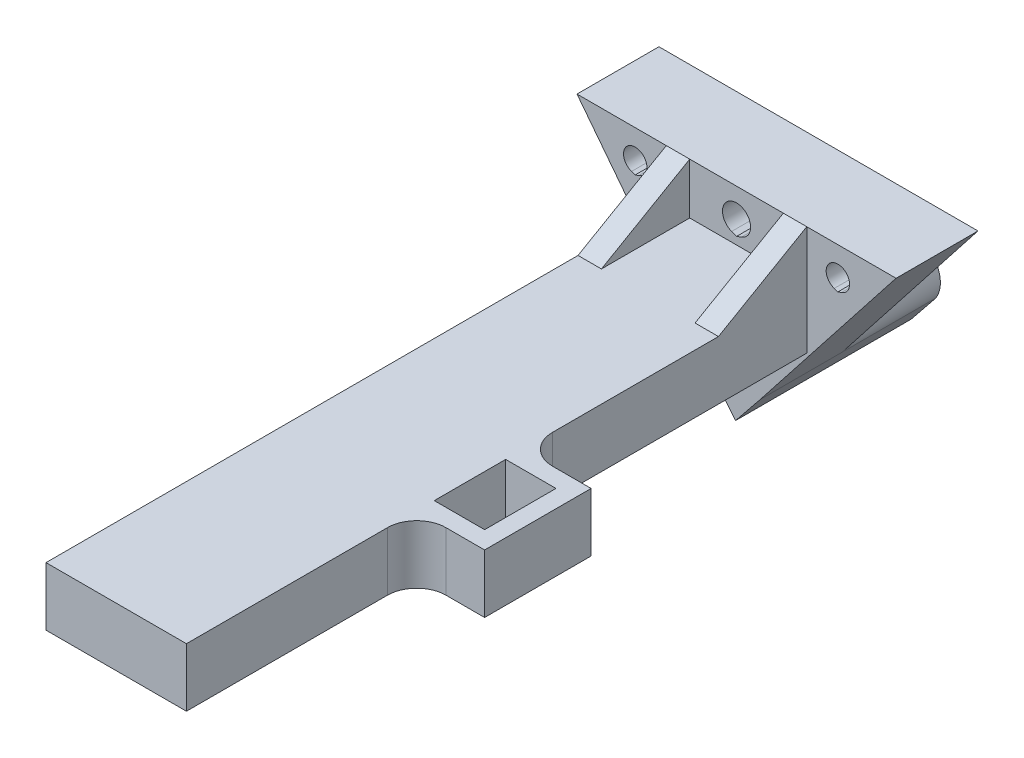
from build123d import *

# Parameters (mm, degrees)
SKETCH1_W            = 12
SKETCH1_H            = 60
BOSS_EXTRUDE1_DEPTH  = 1
SKETCH4_W            = 12
SKETCH4_H            = 60
BOSS_EXTRUDE5_DEPTH  = 4
SKETCH3_W            = 0.442585723
SKETCH3_H            = 46.400729484
SKETCH3_W_2          = 0.4
CUT_EXTRUDE1_DEPTH   = 3
BOSS_EXTRUDE6_DEPTH  = 7
BOSS_EXTRUDE11_DEPTH = 8
BOSS_EXTRUDE12_DEPTH = 2
BOSS_EXTRUDE13_DEPTH = 0.75
BOSS_EXTRUDE15_DEPTH = 2
BOSS_EXTRUDE16_DEPTH = 5
FILLET1_R            = 2.5
FILLET2_R            = 2.5


with BuildPart() as part:
    # Sketch1 → Boss-Extrude1 (new body)
    with BuildSketch(Plane(origin=(0, 0, 0), x_dir=(1, 0, 0), z_dir=(0, 1, 0))):
        with Locations((-1.342029662, -10.461538462)):
            Rectangle(SKETCH1_W, SKETCH1_H)
    extrude(amount=BOSS_EXTRUDE1_DEPTH)

    # Sketch4 → Boss-Extrude5 (add)
    with BuildSketch(Plane(origin=(0, 0, 0), x_dir=(1, 0, 0), z_dir=(0, 1, 0))):
        with Locations((-1.342029662, -10.461538462)):
            Rectangle(SKETCH4_W, SKETCH4_H)
        Polygon((-2.096130055, -33.457130572), (-6.384615385, -37.75443168), (-6.384611455, -29.168649172), align=None, mode=Mode.SUBTRACT)
        Polygon((2.908277834, -38.461538462), (-5.677508603, -38.461538462), (-1.384615385, -34.168645243), align=None, mode=Mode.SUBTRACT)
        Polygon((-1.38975443, -32.749302861), (-5.677336591, -28.461186458), (-1.384615385, -24.168121227), (2.898997747, -28.451734358), align=None, mode=Mode.SUBTRACT)
        Polygon((-2.091498793, -23.461237818), (-6.384610808, -27.754427103), (-6.384606877, -19.168129734), align=None, mode=Mode.SUBTRACT)
        Polygon((-1.384401984, -22.754128282), (-5.676963509, -18.461572954), (-1.384618257, -14.16814285), (2.90844487, -18.461204162), align=None, mode=Mode.SUBTRACT)
        Polygon((-2.094846949, -13.457914458), (-6.38460623, -17.742175237), (-6.38460623, -9.168156991), align=None, mode=Mode.SUBTRACT)
        Polygon((3.615384615, -29.168645243), (3.615384615, -37.75443168), (-0.749170508, -33.533200366), align=None, mode=Mode.SUBTRACT)
        Polygon((3.615384615, -19.168465252), (3.615384615, -27.753907665), (-0.677336591, -23.461186458), align=None, mode=Mode.SUBTRACT)
        Polygon((3.615384615, -17.754251693), (-0.676897524, -13.461506969), (3.615384615, -9.169224829), align=None, mode=Mode.SUBTRACT)
        Polygon((-6.384597723, 0.832144172), (-2.091409836, -3.461043715), (-6.384601653, -7.753916614), align=None, mode=Mode.SUBTRACT)
        Polygon((2.908517821, -8.460971372), (-1.387204346, -12.751178894), (-5.677010576, -8.461229413), (-1.384615385, -4.167838166), align=None, mode=Mode.SUBTRACT)
        Polygon((-1.385221722, -2.75490806), (-5.679497842, 1.537745361), (-1.38541394, 5.831829263), (2.908210299, 1.538205024), align=None, mode=Mode.SUBTRACT)
        Polygon((-2.089578329, 6.535993652), (-6.3837953, 2.241776681), (-6.384597078, 2.240974904), (-6.384597078, 2.242578156), (-6.384593146, 10.83100847), align=None, mode=Mode.SUBTRACT)
        Polygon((-5.677832652, 11.538461538), (2.912889557, 11.538461538), (-1.382471548, 7.243100433), align=None, mode=Mode.SUBTRACT)
        Polygon((3.615384615, -7.755011267), (-0.677821818, -3.462040655), (3.615384615, 0.831165778), align=None, mode=Mode.SUBTRACT)
        Polygon((3.615384615, 2.245379341), (-0.678307159, 6.538936044), (3.615384615, 10.832627818), align=None, mode=Mode.SUBTRACT)
    extrude(amount=-BOSS_EXTRUDE5_DEPTH)

    # Sketch3 → Cut-Extrude1 (cut)
    with BuildSketch(Plane.XZ.offset(4)):
        with Locations((3.436677476, 13.26117372)):
            Rectangle(SKETCH3_W, SKETCH3_H)
        with Locations((-6.184615385, 13.26117372)):
            Rectangle(SKETCH3_W_2, SKETCH3_H)
    extrude(amount=-CUT_EXTRUDE1_DEPTH, mode=Mode.SUBTRACT)

    # Sketch5 → Boss-Extrude6 (add)
    with BuildSketch(Plane(origin=(0, 0, -19.538461538), x_dir=(-1, 0, 0), z_dir=(0, 0, -1))):
        Polygon((-12.288789064, 5.355892869), (14.972848388, 5.355892869), (3.537352374, -9.415920613), (1.425918842, -12.033387248), (-0.689767913, -9.409188123), align=None)
        with BuildLine():
            Line((9.692725832, 1.966121199), (9.999443939, 1.857726092))
            Line((9.999443939, 1.857726092), (10.306162047, 1.966121199))
            ThreePointArc((10.306162047, 1.966121199), (9.999443939, 3.917921599), (9.692725832, 1.966121199))
        make_face(mode=Mode.SUBTRACT)
        with BuildLine():
            Line((-7.622102723, 1.966121199), (-7.315384615, 1.857726092))
            Line((-7.315384615, 1.857726092), (-7.008666508, 1.966121199))
            ThreePointArc((-7.008666508, 1.966121199), (-7.315384615, 3.917921599), (-7.622102723, 1.966121199))
        make_face(mode=Mode.SUBTRACT)
        with BuildLine():
            Line((0.921478569, 1.79402802), (1.342029662, 1.636661499))
            Line((1.342029662, 1.636661499), (1.762580755, 1.79402802))
            ThreePointArc((1.762580755, 1.79402802), (1.342029662, 4.117921599), (0.921478569, 1.79402802))
        make_face(mode=Mode.SUBTRACT)
    extrude(amount=-BOSS_EXTRUDE6_DEPTH)

    # Sketch5_3 → Boss-Extrude11 (add)
    with BuildSketch(Plane(origin=(0, 0, -19.538461538), x_dir=(-1, 0, 0), z_dir=(0, 0, -1))):
        with BuildLine():
            Line((3.537352374, -9.415920613), (1.425918842, -12.033387248))
            Line((1.425918842, -12.033387248), (-0.689767913, -9.409188123))
            ThreePointArc((-0.689767913, -9.409188123), (1.429900561, -5.57732435), (3.537352374, -9.415920613))
        make_face()
    extrude(amount=BOSS_EXTRUDE11_DEPTH)

    # Sketch11 → Boss-Extrude12 (add)
    with BuildSketch(Plane.ZY.offset(7.342029662)):
        Polygon((-12.538461538, 5.355892869), (-4.993833778, 1), (-12.538461538, 1), align=None)
    extrude(amount=-BOSS_EXTRUDE12_DEPTH)

    # Sketch12 → Boss-Extrude13 (add, symmetric)
    with BuildSketch(Plane.ZY.offset(1.342029662)):
        Polygon((-13.859142787, 0.316720052), (-13.859142787, -4.418628297), (-13.859142787, -9.68323793), (-6.410996577, -3.888931374), (-6.410996577, 0.316720052), align=None)
    extrude(amount=BOSS_EXTRUDE13_DEPTH, both=True)

    # Sketch14 → Boss-Extrude15 (add)
    with BuildSketch(Plane(origin=(4.657970338, 0, 0), x_dir=(0, 0, -1), z_dir=(1, 0, 0))):
        Polygon((4.993833778, 1), (12.538461538, 5.355892869), (12.538461538, 1), align=None)
    extrude(amount=-BOSS_EXTRUDE15_DEPTH)

    # Sketch15 → Boss-Extrude16 (add)
    with BuildSketch(Plane(origin=(0, 1, 0), x_dir=(1, 0, 0), z_dir=(0, 1, 0))):
        Polygon((4.657970338, -11.687539089), (4.657970338, -13.187539089), (8.957970338, -13.187539089), (8.957970338, -19.287539089), (4.657970338, -19.287539089), (4.657970338, -20.787539089), (10.457970338, -20.787539089), (10.457970338, -11.687539089), align=None)
    extrude(amount=-BOSS_EXTRUDE16_DEPTH)

    # Fillet1
    fillet1_edges = [part.edges().sort_by_distance(p)[0] for p in [
        (4.657970338, -1.5, 20.787539089),
    ]]
    fillet(fillet1_edges, radius=FILLET1_R)

    # Fillet2
    fillet2_edges = [part.edges().sort_by_distance(p)[0] for p in [
        (4.657970338, -1.5, 11.687539089),
    ]]
    fillet(fillet2_edges, radius=FILLET2_R)


solid = part.part
